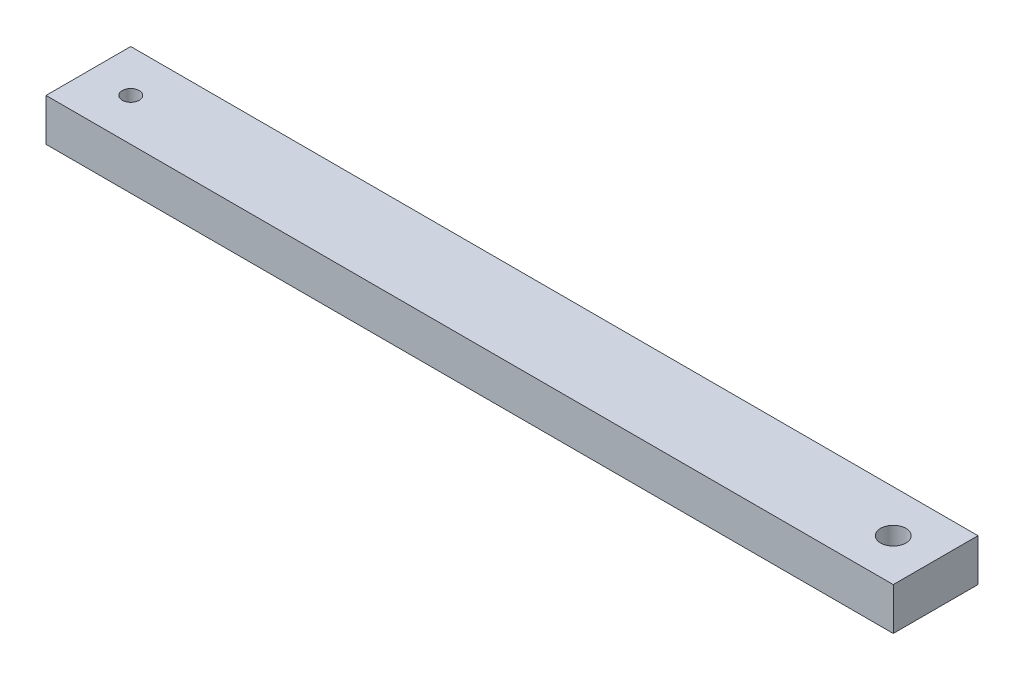
from build123d import *

# Parameters (mm, degrees)
CROQUIS1_W              = 100
CROQUIS1_H              = 5
SALIENTE_EXTRUIR1_DEPTH = 10
CROQUIS2_R              = 1
CROQUIS2_R_2            = 1.5
CORTAR_EXTRUIR1_DEPTH   = 10


with BuildPart() as part:
    # Croquis1 → Saliente-Extruir1 (new body)
    with BuildSketch(Plane.XY):
        with Locations((50, 2.5)):
            Rectangle(CROQUIS1_W, CROQUIS1_H)
    extrude(amount=SALIENTE_EXTRUIR1_DEPTH)

    # Croquis2 → Cortar-Extruir1 (cut)
    with BuildSketch(Plane(origin=(0, 5, 0), x_dir=(1, 0, 0), z_dir=(0, 1, 0))):
        with Locations(Location((5, -5, 0), (0, 0, 270))):  # turned: the seam where the file's is
            Circle(CROQUIS2_R)
        with Locations(Location((95, -5, 0), (0, 0, 270))):  # turned: the seam where the file's is
            Circle(CROQUIS2_R_2)
    extrude(amount=-CORTAR_EXTRUIR1_DEPTH, mode=Mode.SUBTRACT)


solid = part.part
